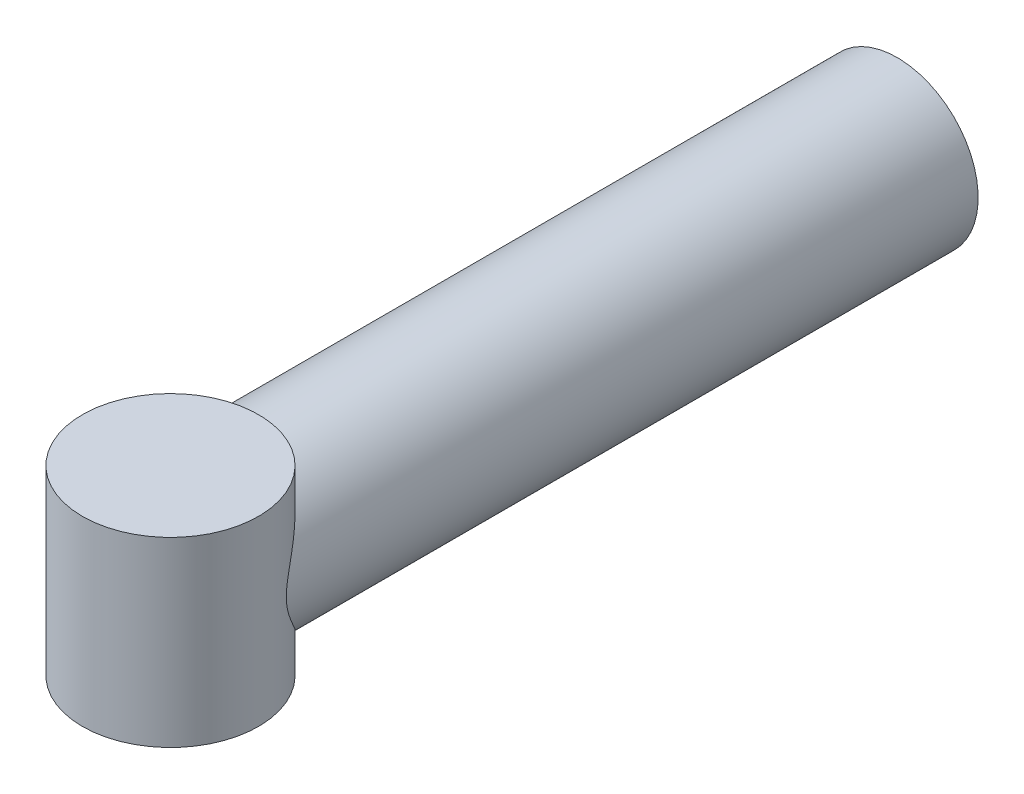
from build123d import *

# Parameters (mm, degrees)
SKETCH1_R           = 20
SKETCH1_R_2         = 15
BOSS_EXTRUDE1_DEPTH = 80
SKETCH7_R           = 20
SKETCH7_R_2         = 15
BOSS_EXTRUDE4_DEPTH = 100
SKETCH8_R           = 21.789778514
BOSS_EXTRUDE5_DEPTH = 22.5


with BuildPart() as part:
    # Sketch1 → Boss-Extrude1 (new body)
    with BuildSketch(Plane.XY):
        Circle(SKETCH1_R)
        Circle(SKETCH1_R_2, mode=Mode.SUBTRACT)
    extrude(amount=BOSS_EXTRUDE1_DEPTH)

    # Sketch7 → Boss-Extrude4 (add)
    with BuildSketch(Plane(origin=(0, 0, 0), x_dir=(-1, 0, 0), z_dir=(0, 0, -1))):
        Circle(SKETCH7_R)
        Circle(SKETCH7_R_2, mode=Mode.SUBTRACT)
    extrude(amount=BOSS_EXTRUDE4_DEPTH)

    # Sketch8 → Boss-Extrude5 (add, symmetric)
    with BuildSketch(Plane(origin=(0, 0, 0), x_dir=(1, 0, 0), z_dir=(0, 1, 0))):
        with Locations((0, -79.738438167)):
            Circle(SKETCH8_R)
    extrude(amount=BOSS_EXTRUDE5_DEPTH, both=True)


solid = part.part
